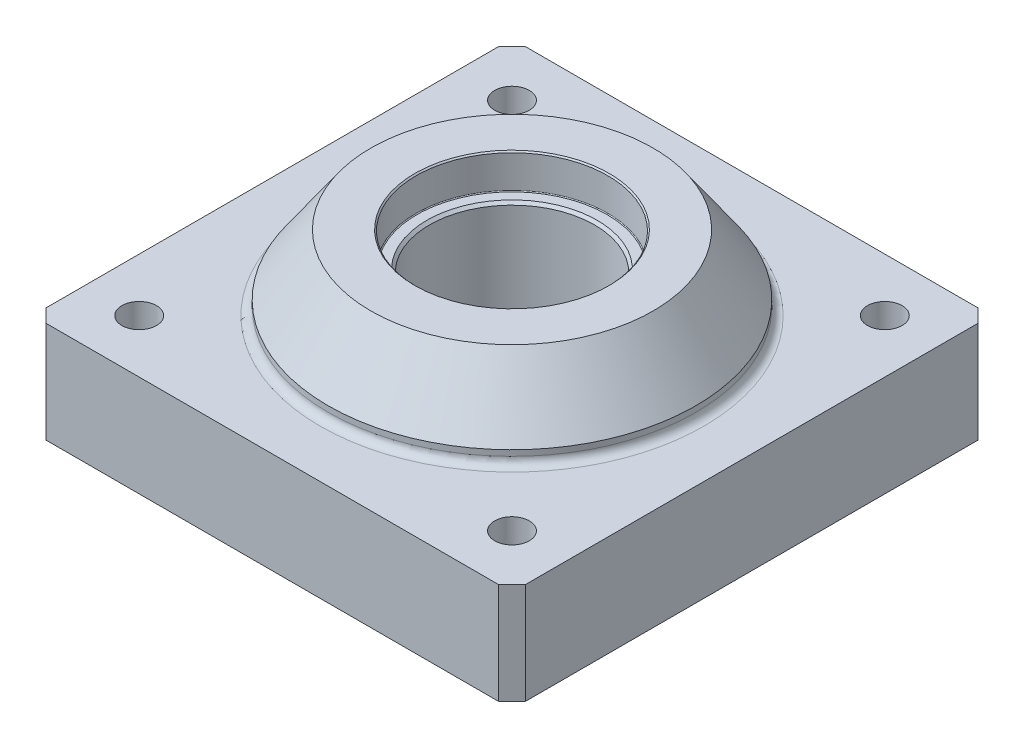
from build123d import *

# Parameters (mm, degrees)
SKETCH1_W            = 180
SKETCH1_H            = 180
BOSS_EXTRUDE1_DEPTH  = 38
SKETCH2_R            = 69
BOSS_EXTRUDE2_DEPTH  = 28
CHAMFER3_SIZE        = 16
CHAMFER3_SIZE2       = 22.850368108
SKETCH3_R            = 36
CUT_EXTRUDE1_DEPTH   = 13
CUT_EXTRUDE2_REACH   = 145.374
SKETCH4_R            = 31
CUT_EXTRUDE3_REACH   = 134.831
SKETCH5_R            = 6.5
LPATTERN1_COUNT      = 2
LPATTERN1_PITCH      = 140
LPATTERN1_COUNT_DIR2 = 2
LPATTERN1_PITCH_DIR2 = 140
CHAMFER4_SIZE        = 5
CHAMFER5_SIZE        = 1
CHAMFER6_SIZE        = 0.5
FILLET1_R            = 0.3
FILLET2_R            = 3


with BuildPart() as part:
    # Sketch1 → Boss-Extrude1 (new body)
    with BuildSketch(Plane(origin=(0, 0, 0), x_dir=(1, 0, 0), z_dir=(0, 1, 0))):
        Rectangle(SKETCH1_W, SKETCH1_H)
    extrude(amount=BOSS_EXTRUDE1_DEPTH)

    # Sketch2 → Boss-Extrude2 (add)
    with BuildSketch(Plane(origin=(0, 38, 0), x_dir=(1, 0, 0), z_dir=(0, 1, 0))):
        Circle(SKETCH2_R)
    extrude(amount=BOSS_EXTRUDE2_DEPTH)

    # Chamfer3
    chamfer3_edges = [part.edges().sort_by_distance(p)[0] for p in [
        (-69, 66, 0),
    ]]
    chamfer3_side = [part.faces().sort_by_distance(p)[0] for p in [
        (0, 66, 0),
    ]]
    chamfer(chamfer3_edges, length=CHAMFER3_SIZE, length2=CHAMFER3_SIZE2, reference=chamfer3_side[0])

    # Sketch3 → Cut-Extrude1 (cut)
    with BuildSketch(Plane(origin=(0, 66, 0), x_dir=(1, 0, 0), z_dir=(0, 1, 0))):
        Circle(SKETCH3_R)
    extrude(amount=-CUT_EXTRUDE1_DEPTH, mode=Mode.SUBTRACT)

    # Sketch4 → Cut-Extrude2 (cut, up to next)
    with BuildSketch(Plane(origin=(0, 0, 0), x_dir=(-1, 0, 0), z_dir=(0, -1, 0)), mode=Mode.PRIVATE) as cut_extrude2_sk1:
        Circle(SKETCH4_R)
    cut_extrude2_tool1 = extrude(cut_extrude2_sk1.sketch, amount=-CUT_EXTRUDE2_REACH, mode=Mode.PRIVATE) & part.part
    add(cut_extrude2_tool1.solids().sort_by_distance((0, 0, 0))[0], mode=Mode.SUBTRACT)

    # Sketch5 → Cut-Extrude3 (cut, up to next)
    with BuildSketch(Plane(origin=(0, 38, 0), x_dir=(1, 0, 0), z_dir=(0, 1, 0)), mode=Mode.PRIVATE) as cut_extrude3_sk1:
        with Locations((-70, 70)):
            Circle(SKETCH5_R)
    cut_extrude3_tool1 = extrude(cut_extrude3_sk1.sketch, amount=-CUT_EXTRUDE3_REACH, mode=Mode.PRIVATE) & part.part
    cut_extrude3 = cut_extrude3_tool1.solids().sort_by_distance((-70, 38, -70))[0]
    add(cut_extrude3, mode=Mode.SUBTRACT)

    # LPattern1: Cut-Extrude3 2 × 2
    with Locations(*[(i * LPATTERN1_PITCH, 0, j * LPATTERN1_PITCH_DIR2) for i in range(LPATTERN1_COUNT) for j in range(LPATTERN1_COUNT_DIR2) if (i, j) != (0, 0)]):
        add(cut_extrude3, mode=Mode.SUBTRACT)

    # Chamfer4
    chamfer4_edges = [part.edges().sort_by_distance(p)[0] for p in [
        (-90, 19, -90),
        (90, 19, -90),
        (-90, 19, 90),
        (90, 19, 90),
    ]]
    chamfer(chamfer4_edges, length=CHAMFER4_SIZE)

    # Chamfer5
    chamfer5_edges = [part.edges().sort_by_distance(p)[0] for p in [
        (31, 0, 0),
        (31, 53, 0),
    ]]
    chamfer(chamfer5_edges, length=CHAMFER5_SIZE)

    # Chamfer6
    chamfer6_edges = [part.edges().sort_by_distance(p)[0] for p in [
        (-36, 66, 0),
    ]]
    chamfer(chamfer6_edges, length=CHAMFER6_SIZE)

    # Fillet1
    fillet1_edges = [part.edges().sort_by_distance(p)[0] for p in [
        (-36, 53, 0),
    ]]
    fillet(fillet1_edges, radius=FILLET1_R)

    # Fillet2
    fillet2_edges = [part.edges().sort_by_distance(p)[0] for p in [
        (-69, 38, 0),
    ]]
    fillet(fillet2_edges, radius=FILLET2_R)


solid = part.part
